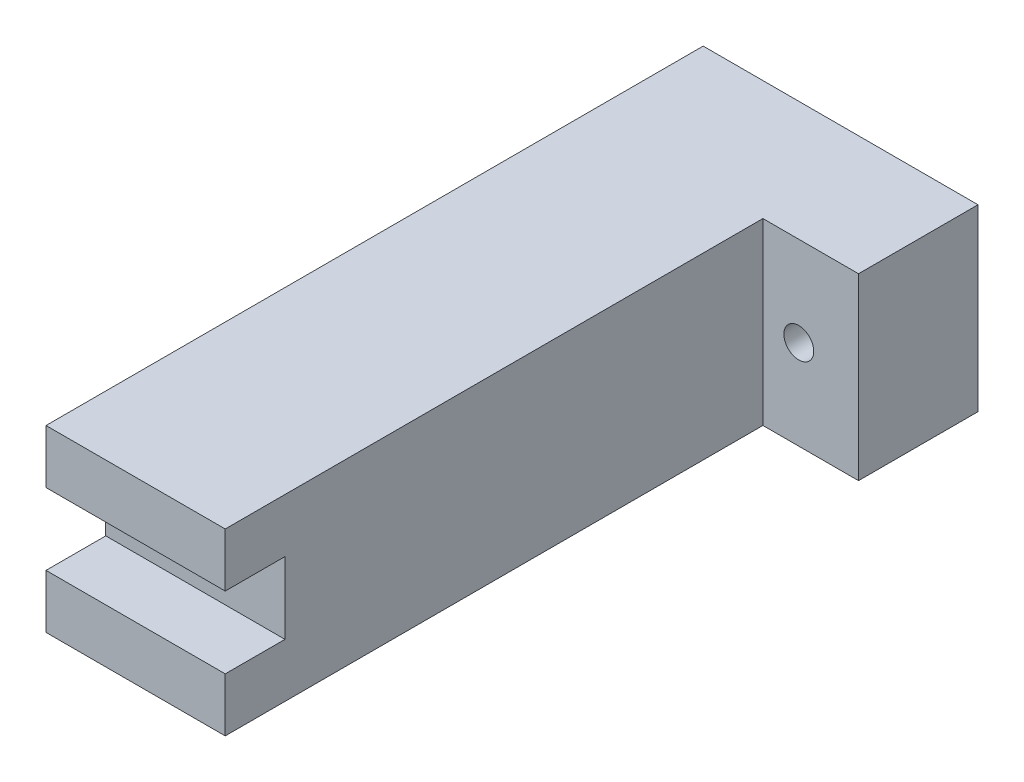
from build123d import *

# Parameters (mm, degrees)
EXTRUDE_1_DEPTH          = 30
SKETCH_2_R               = 2.5
CUT_EXTRUDE_1_DEPTH      = 21
CUT_EXTRUDE_2_DEPTH      = 1
CUT_EXTRUDE_2_DEPTH_BACK = 47


with BuildPart() as part:
    # Эскиз1 → Бобышка-Вытянуть1 (new body)
    with BuildSketch(Plane(origin=(0, 0, 0), x_dir=(1, 0, 0), z_dir=(0, 1, 0))):
        Polygon((0, 0), (0, -90), (-30, -90), (-30, 20), (16, 20), (16, 0), align=None)
    extrude(amount=EXTRUDE_1_DEPTH)

    # Эскиз2 → Вырез-Вытянуть1 (cut, through all)
    with BuildSketch(Plane.XY):
        with Locations((6, 15)):
            Circle(SKETCH_2_R)
    extrude(amount=-CUT_EXTRUDE_1_DEPTH, mode=Mode.SUBTRACT)

    # Эскиз3 → Вырез-Вытянуть2 (cut, two sides)
    with BuildSketch(Plane.ZY.offset(30)) as cut_extrude_2_sk:
        Polygon((323.973212684, 21), (90, 21), (80, 21), (80, 9), (90, 9), (323.973212684, 9), (791.919638052, 9), (791.919638052, 21), align=None)
    extrude(amount=CUT_EXTRUDE_2_DEPTH, mode=Mode.SUBTRACT)
    extrude(cut_extrude_2_sk.sketch, amount=-CUT_EXTRUDE_2_DEPTH_BACK, mode=Mode.SUBTRACT)


solid = part.part
